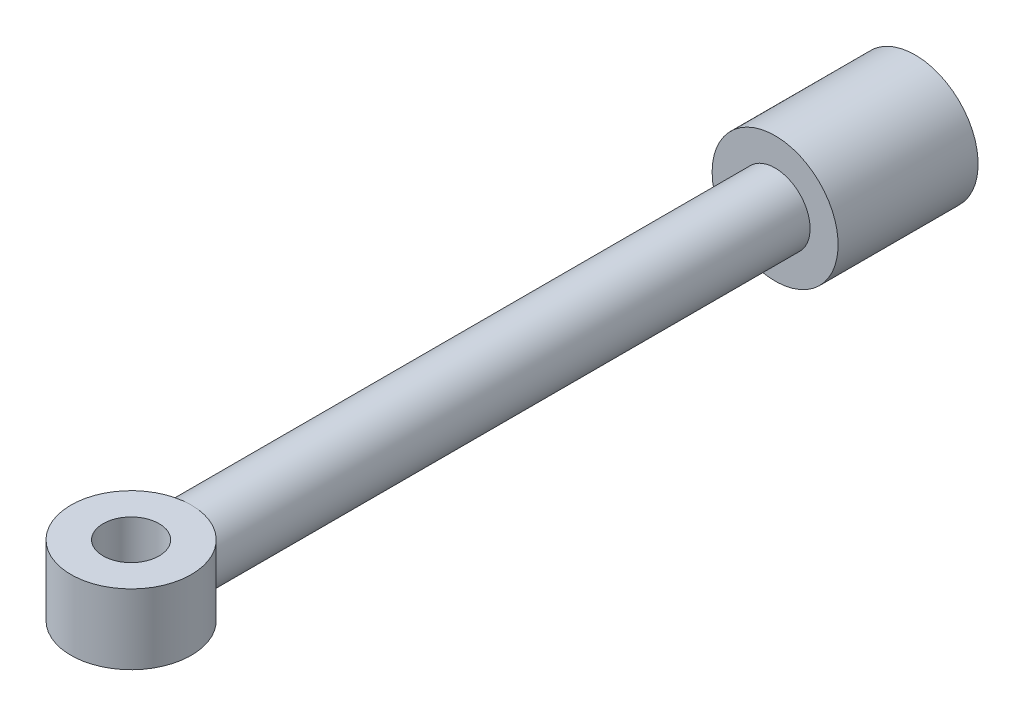
from build123d import *

# Parameters (mm, degrees)
SKETCH3_R           = 43
SKETCH3_R_2         = 20
BOSS_EXTRUDE1_DEPTH = 25


with BuildPart() as part:
    # Sketch1 → Revolve1 (revolve)
    with BuildSketch(Plane(origin=(0, 0, 0), x_dir=(1, 0, 0), z_dir=(0, 1, 0))):
        Polygon((0, -75), (45, -75), (45, -175), (25, -175), (25, -600.014288631), (0, -600.014288631), align=None)
    revolve(axis=Axis((0, 0, 75), (0, 0, 1)))

    # Sketch3 → Boss-Extrude1 (add, symmetric)
    with BuildSketch(Plane(origin=(0, 0, 0), x_dir=(1, 0, 0), z_dir=(0, 1, 0))):
        with Locations((0, -635)):
            Circle(SKETCH3_R)
        with Locations((0, -635)):
            Circle(SKETCH3_R_2, mode=Mode.SUBTRACT)
    extrude(amount=BOSS_EXTRUDE1_DEPTH, both=True)


solid = part.part
